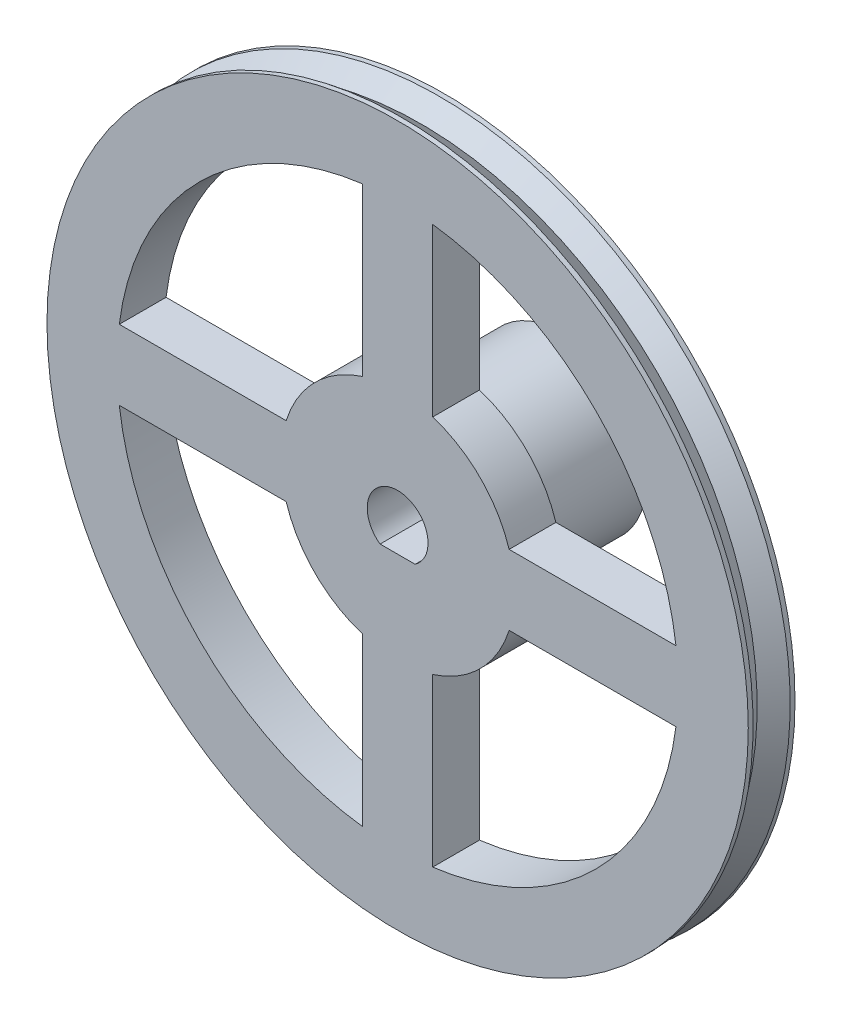
from build123d import *

# Parameters (mm, degrees)
CROQUIS1_R              = 30
SALIENTE_EXTRUIR1_DEPTH = 4
CROQUIS4_R              = 7.319391613
SALIENTE_EXTRUIR2_DEPTH = 10
CORTAR_EXTRUIR1_DEPTH   = 10
CORTAR_EXTRUIR2_DEPTH   = 15


with BuildPart() as part:
    # Croquis1 → Saliente-Extruir1 (new body)
    with BuildSketch(Plane.XY):
        Circle(CROQUIS1_R)
    extrude(amount=SALIENTE_EXTRUIR1_DEPTH)

    # Croquis3 → Cortar-Revolución1 (revolve, cut)
    with BuildSketch(Plane(origin=(0, 0, 0), x_dir=(1, 0, 0), z_dir=(0, 1, 0))):
        Polygon((-30, -4), (-30, -3.587135196), (-28.759048166, -2), (-30, -0.412864804), (-30, 0), (-32.403502023, 0), (-32.403502023, -4), align=None)
    revolve(axis=Axis((0, 0, -0.500745856), (0, 0, 1)), mode=Mode.SUBTRACT)

    # Croquis4 → Saliente-Extruir2 (add)
    with BuildSketch(Plane(origin=(0, 0, 0), x_dir=(-1, 0, 0), z_dir=(0, 0, -1))):
        Circle(CROQUIS4_R)
    extrude(amount=SALIENTE_EXTRUIR2_DEPTH)

    # Croquis5 → Cortar-Extruir1 (cut)
    with BuildSketch(Plane(origin=(0, 0, 0), x_dir=(-1, 0, 0), z_dir=(0, 0, -1))):
        with BuildLine():
            Line((-23.8117618, -3), (-9.539392014, -3))
            ThreePointArc((-9.539392014, -3), (-7.071067812, -7.071067812), (-3, -9.539392014))
            Line((-3, -9.539392014), (-3, -23.8117618))
            ThreePointArc((-3, -23.8117618), (-16.970562748, -16.970562748), (-23.8117618, -3))
        make_face()
        with BuildLine():
            Line((-23.8117618, 3), (-9.539392014, 3))
            ThreePointArc((-9.539392014, 3), (-7.071067812, 7.071067812), (-3, 9.539392014))
            Line((-3, 9.539392014), (-3, 23.8117618))
            ThreePointArc((-3, 23.8117618), (-16.970562748, 16.970562748), (-23.8117618, 3))
        make_face()
        with BuildLine():
            Line((3, 23.8117618), (3, 9.539392014))
            ThreePointArc((3, 9.539392014), (7.071067812, 7.071067812), (9.539392014, 3))
            Line((9.539392014, 3), (23.8117618, 3))
            ThreePointArc((23.8117618, 3), (16.970562748, 16.970562748), (3, 23.8117618))
        make_face()
        with BuildLine():
            Line((23.8117618, -3), (9.539392014, -3))
            ThreePointArc((9.539392014, -3), (7.071067812, -7.071067812), (3, -9.539392014))
            Line((3, -9.539392014), (3, -23.8117618))
            ThreePointArc((3, -23.8117618), (16.970562748, -16.970562748), (23.8117618, -3))
        make_face()
    extrude(amount=-CORTAR_EXTRUIR1_DEPTH, mode=Mode.SUBTRACT)

    # Croquis6 → Cortar-Extruir2 (cut, through all)
    with BuildSketch(Plane(origin=(0, 0, -10), x_dir=(-1, 0, 0), z_dir=(0, 0, -1))):
        with BuildLine():
            Line((1.5, -2.123676058), (-1.5, -2.123676058))
            ThreePointArc((-1.5, -2.123676058), (0, 2.6), (1.5, -2.123676058))
        make_face()
    extrude(amount=-CORTAR_EXTRUIR2_DEPTH, mode=Mode.SUBTRACT)


solid = part.part
